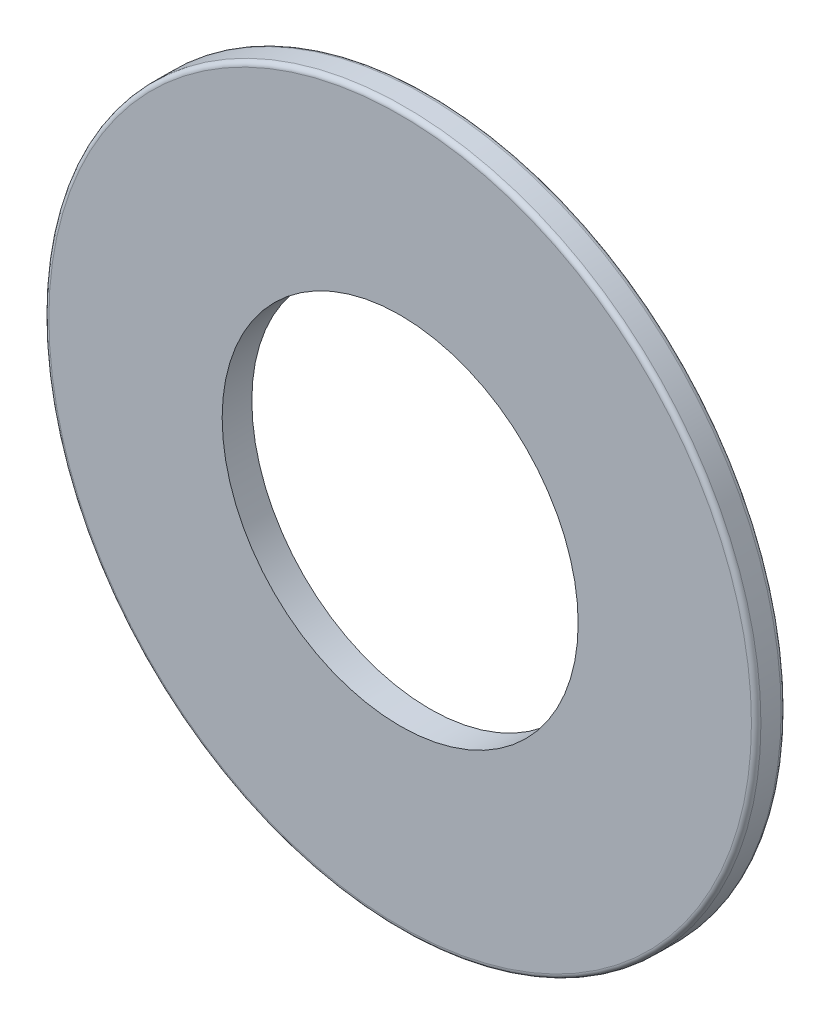
from build123d import *

# Parameters (mm, degrees)
SKETCH1_R           = 9.525
SKETCH1_R_2         = 4.7625
BOSS_EXTRUDE1_DEPTH = 0.79375
FILLET1_R           = 0.127


with BuildPart() as part:
    # Sketch1 → Boss-Extrude1 (new body)
    with BuildSketch(Plane.XY):
        Circle(SKETCH1_R)
        Circle(SKETCH1_R_2, mode=Mode.SUBTRACT)
    extrude(amount=BOSS_EXTRUDE1_DEPTH)

    # Fillet1
    fillet1_edges = [part.edges().sort_by_distance(p)[0] for p in [
        (-9.525, 0, 0),
        (-9.525, 0, 0.79375),
    ]]
    fillet(fillet1_edges, radius=FILLET1_R)


solid = part.part
